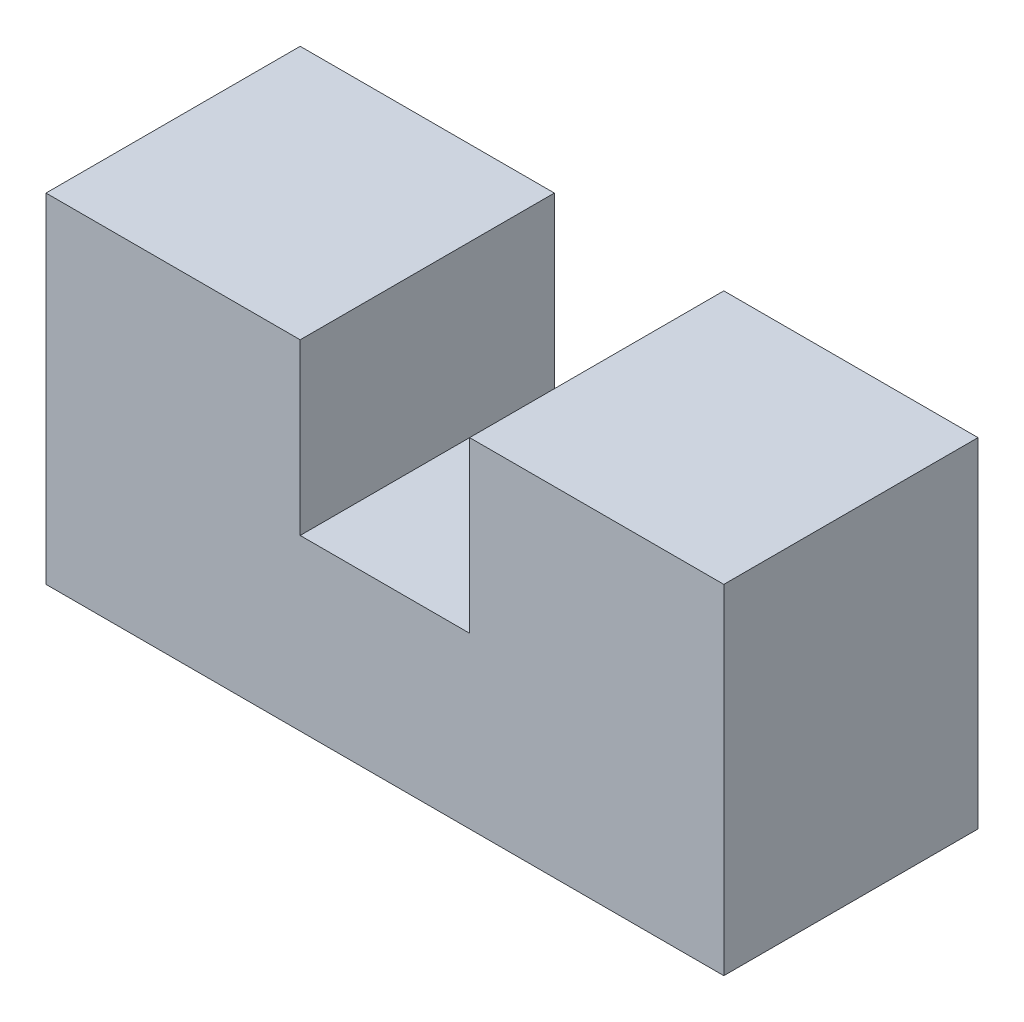
from build123d import *

# Parameters (mm, degrees)
BOSS_EXTRUDE1_DEPTH = 15


with BuildPart() as part:
    # Sketch2 → Boss-Extrude1 (new body, symmetric)
    with BuildSketch(Plane.XY):
        Polygon((0, 0), (0, -40), (80, -40), (80, 0), (50, 0), (50, -20), (30, -20), (30, 0), align=None)
    extrude(amount=BOSS_EXTRUDE1_DEPTH, both=True)


solid = part.part
